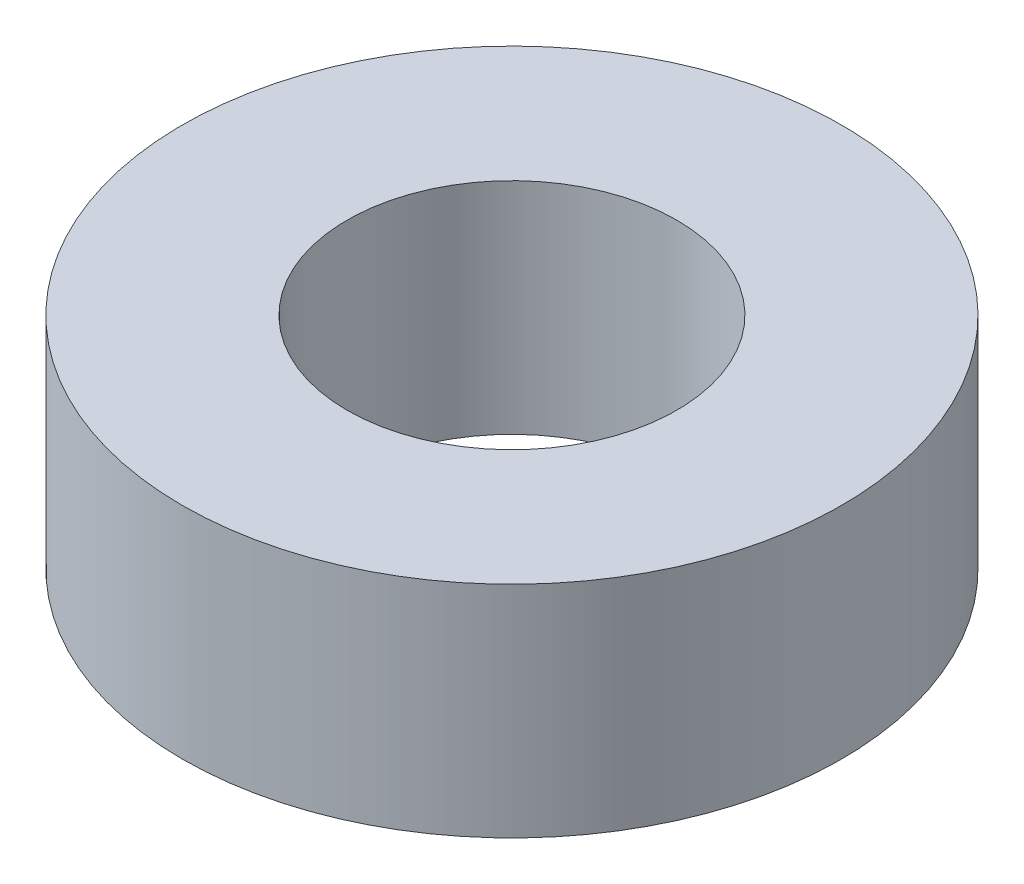
from build123d import *

# Parameters (mm, degrees)
SKETCH1_R           = 6
SKETCH1_R_2         = 3
BOSS_EXTRUDE1_DEPTH = 4


with BuildPart() as part:
    # Sketch1 → Boss-Extrude1 (new body)
    with BuildSketch(Plane(origin=(0, 0, 0), x_dir=(1, 0, 0), z_dir=(0, 1, 0))):
        Circle(SKETCH1_R)
        Circle(SKETCH1_R_2, mode=Mode.SUBTRACT)
    extrude(amount=BOSS_EXTRUDE1_DEPTH)


solid = part.part
